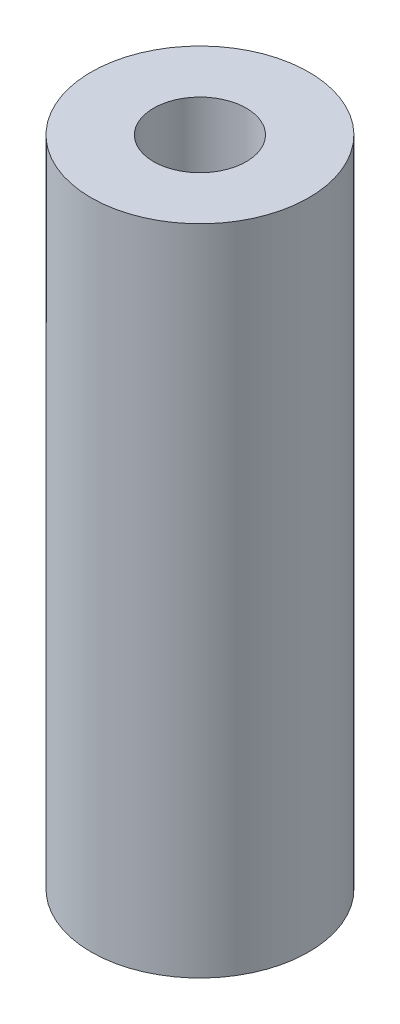
from build123d import *

# Parameters (mm, degrees)
SKETCH1_R                 = 3.175
BOSS_EXTRUDE1_DEPTH       = 19.05
TAP_DRILL_FOR_6_32_TAP1_D = 2.7051


with BuildPart() as part:
    # Sketch1 → Boss-Extrude1 (new body)
    with BuildSketch(Plane(origin=(0, 0, 0), x_dir=(1, 0, 0), z_dir=(0, 1, 0))):
        Circle(SKETCH1_R)
    extrude(amount=BOSS_EXTRUDE1_DEPTH)

    # Tap Drill for #6-32 Tap1 (through all)
    with Locations(Plane(origin=(0, 19.05, 0), x_dir=(1, 0, 0), z_dir=(0, 1, 0))):
        with Locations((0, 0)):
            Hole(TAP_DRILL_FOR_6_32_TAP1_D / 2)


solid = part.part
